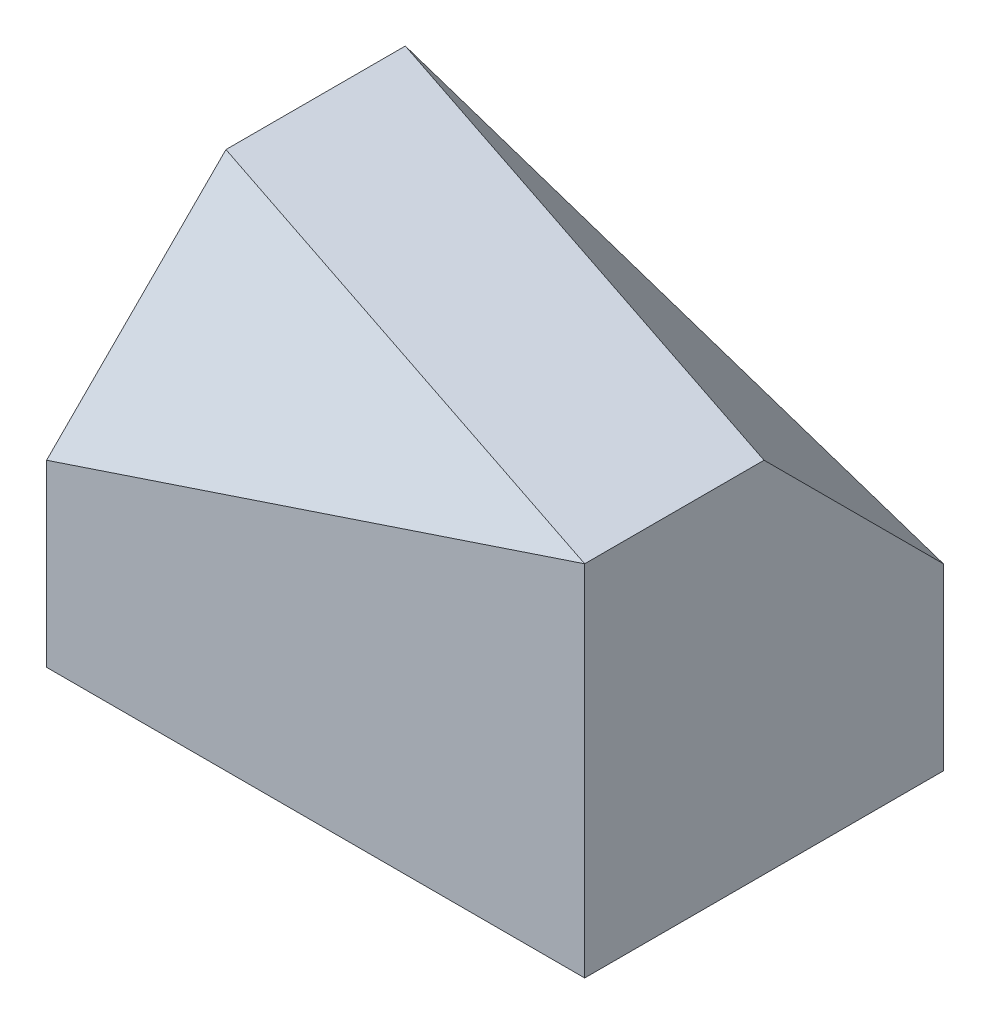
from build123d import *

# Parameters (mm, degrees)
BOSS_EXTRUDE1_DEPTH = 1016


with BuildPart() as part:
    # Sketch1 → Boss-Extrude1 (new body)
    with BuildSketch(Plane(origin=(0, 0, 0), x_dir=(1, 0, 0), z_dir=(0, 1, 0))):
        Polygon((0, 1016), (0, 508), (1524, 0), (1524, 508), align=None)
        Polygon((1524, 1016), (0, 1016), (1524, 508), align=None)
        Polygon((0, 508), (0, 0), (1524, 0), align=None)
    extrude(amount=BOSS_EXTRUDE1_DEPTH)

    # SurfaceCut1
    split(bisect_by=Plane(origin=(320.842105263, 962.526315789, -962.526315789), x_dir=(-0.9733285267845753, 0.16222142113076252, -0.1622214211307626), z_dir=(0.22941573387056174, 0.6882472016116851, -0.6882472016116855)), keep=Keep.BOTTOM)

    # SurfaceCut2
    split(bisect_by=Plane(origin=(-80.210526316, 240.631578947, 240.631578947), x_dir=(0.9733285267845753, 0.16222142113076254, 0.16222142113076254), z_dir=(-0.22941573387056177, 0.6882472016116853, 0.6882472016116854)), keep=Keep.BOTTOM)


solid = part.part
